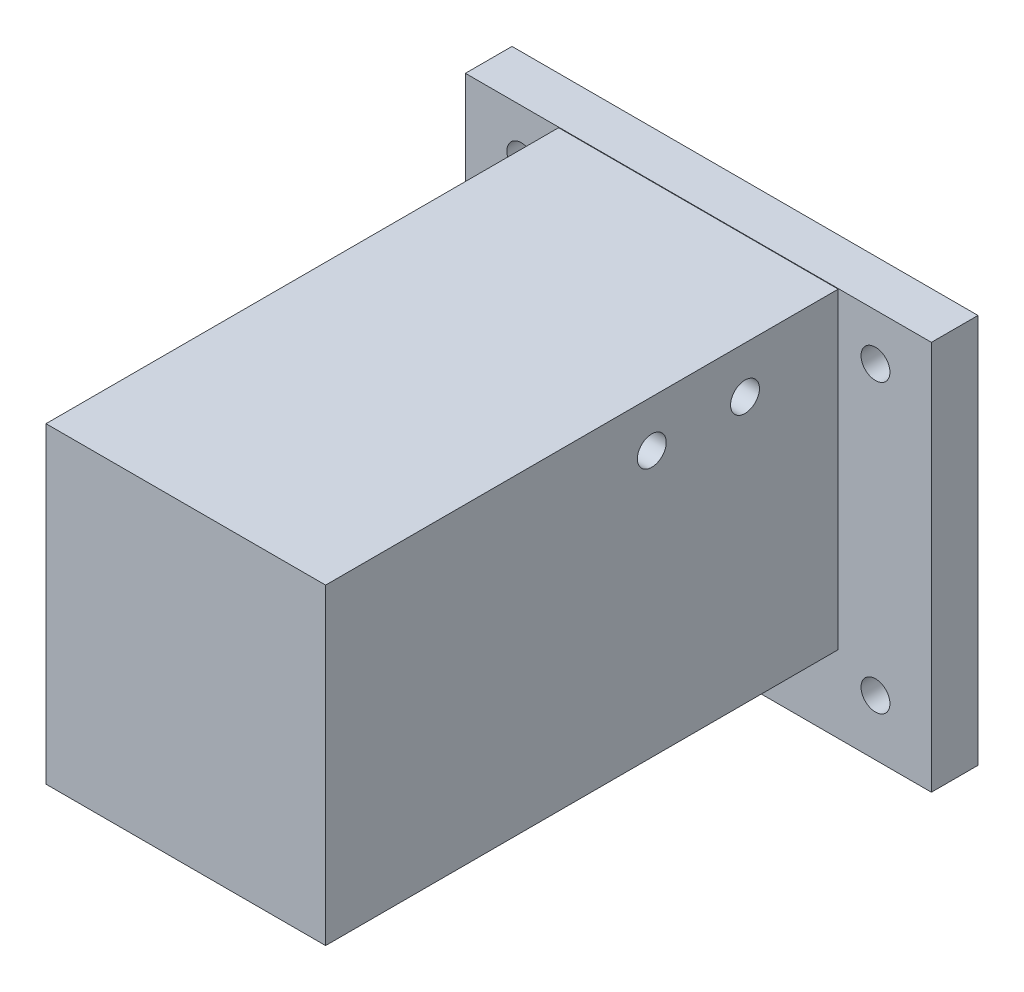
from build123d import *

# Parameters (mm, degrees)
SKETCH3_W               = 50
SKETCH3_H               = 50
BOSS_EXTRUDE1_DEPTH     = 5
BOSS_EXTRUDE4_START     = 5
SKETCH4_W               = 30
SKETCH4_H               = 33.5
BOSS_EXTRUDE4_DEPTH     = 70
CUT_EXTRUDE1_START      = 2
SKETCH6_W               = 20
SKETCH6_H               = 41
CUT_EXTRUDE1_DEPTH      = 19
SKETCH7_W               = 30
SKETCH7_H               = 15
CUT_EXTRUDE2_DEPTH      = 26
CUT_EXTRUDE2_DEPTH_BACK = 26
SKETCH9_R               = 1.55
CUT_EXTRUDE4_DEPTH      = 26
CUT_EXTRUDE4_DEPTH_BACK = 26
SKETCH10_R              = 1.55
CUT_EXTRUDE6_DEPTH      = 61
CUT_EXTRUDE6_DEPTH_BACK = 1
SKETCH11_W              = 50
SKETCH11_H              = 8.193147868
CUT_EXTRUDE7_DEPTH      = 25
SKETCH12_R              = 1.55
CUT_EXTRUDE8_DEPTH      = 61
CUT_EXTRUDE8_DEPTH_BACK = 25


with BuildPart() as part:
    # Sketch3 → Boss-Extrude1 (new body)
    with BuildSketch(Plane.XY):
        Rectangle(SKETCH3_W, SKETCH3_H)
    extrude(amount=BOSS_EXTRUDE1_DEPTH)

    # Sketch4 → Boss-Extrude4 (add)
    with BuildSketch(Plane.XY.offset(BOSS_EXTRUDE4_START)):
        Rectangle(SKETCH4_W, SKETCH4_H)
    extrude(amount=BOSS_EXTRUDE4_DEPTH)

    # Sketch6 → Cut-Extrude1 (cut)
    with BuildSketch(Plane(origin=(0, 0, 0), x_dir=(1, 0, 0), z_dir=(0, 1, 0)).offset(CUT_EXTRUDE1_START)):
        with Locations((0, -35.5)):
            Rectangle(SKETCH6_W, SKETCH6_H)
    extrude(amount=-CUT_EXTRUDE1_DEPTH, mode=Mode.SUBTRACT)

    # Sketch7 → Cut-Extrude2 (cut, two sides)
    with BuildSketch(Plane(origin=(0, 0, 0), x_dir=(1, 0, 0), z_dir=(0, 1, 0))) as cut_extrude2_sk:
        with Locations((0, -67.5)):
            Rectangle(SKETCH7_W, SKETCH7_H)
    extrude(amount=CUT_EXTRUDE2_DEPTH, mode=Mode.SUBTRACT)
    extrude(cut_extrude2_sk.sketch, amount=-CUT_EXTRUDE2_DEPTH_BACK, mode=Mode.SUBTRACT)

    # Sketch9 → Cut-Extrude4 (cut, two sides)
    with BuildSketch(Plane(origin=(0, 0, 0), x_dir=(0, 0, -1), z_dir=(1, 0, 0))) as cut_extrude4_sk:
        with Locations((-25, 11.75)):
            Circle(SKETCH9_R)
        with Locations((-15, 11.75)):
            Circle(SKETCH9_R)
    extrude(amount=CUT_EXTRUDE4_DEPTH, mode=Mode.SUBTRACT)
    extrude(cut_extrude4_sk.sketch, amount=-CUT_EXTRUDE4_DEPTH_BACK, mode=Mode.SUBTRACT)

    # Sketch10 → Cut-Extrude6 (cut, two sides)
    with BuildSketch(Plane.XY) as cut_extrude6_sk:
        with BuildLine():
            Line((-20.096015511, 20.096015511), (-17.903984489, 17.903984489))
            ThreePointArc((-17.903984489, 17.903984489), (-17.903984489, 20.096015511), (-20.096015511, 20.096015511))
        make_face()
        with Locations((19, 19)):
            Circle(SKETCH10_R)
        with Locations((19, -19)):
            Circle(SKETCH10_R)
        with Locations((-19, -19)):
            Circle(SKETCH10_R)
    extrude(amount=CUT_EXTRUDE6_DEPTH, mode=Mode.SUBTRACT)
    extrude(cut_extrude6_sk.sketch, amount=-CUT_EXTRUDE6_DEPTH_BACK, mode=Mode.SUBTRACT)

    # Sketch11 → Cut-Extrude7 (cut)
    with BuildSketch(Plane.XY.offset(5)):
        with Locations((0, 20.903426066)):
            Rectangle(SKETCH11_W, SKETCH11_H)
    extrude(amount=-CUT_EXTRUDE7_DEPTH, mode=Mode.SUBTRACT)

    # Sketch12 → Cut-Extrude8 (cut, two sides)
    with BuildSketch(Plane.XY) as cut_extrude8_sk:
        with Locations((-19, 11.806852132)):
            Circle(SKETCH12_R)
        with Locations((19, 11.806852132)):
            Circle(SKETCH12_R)
    extrude(amount=CUT_EXTRUDE8_DEPTH, mode=Mode.SUBTRACT)
    extrude(cut_extrude8_sk.sketch, amount=-CUT_EXTRUDE8_DEPTH_BACK, mode=Mode.SUBTRACT)


solid = part.part
